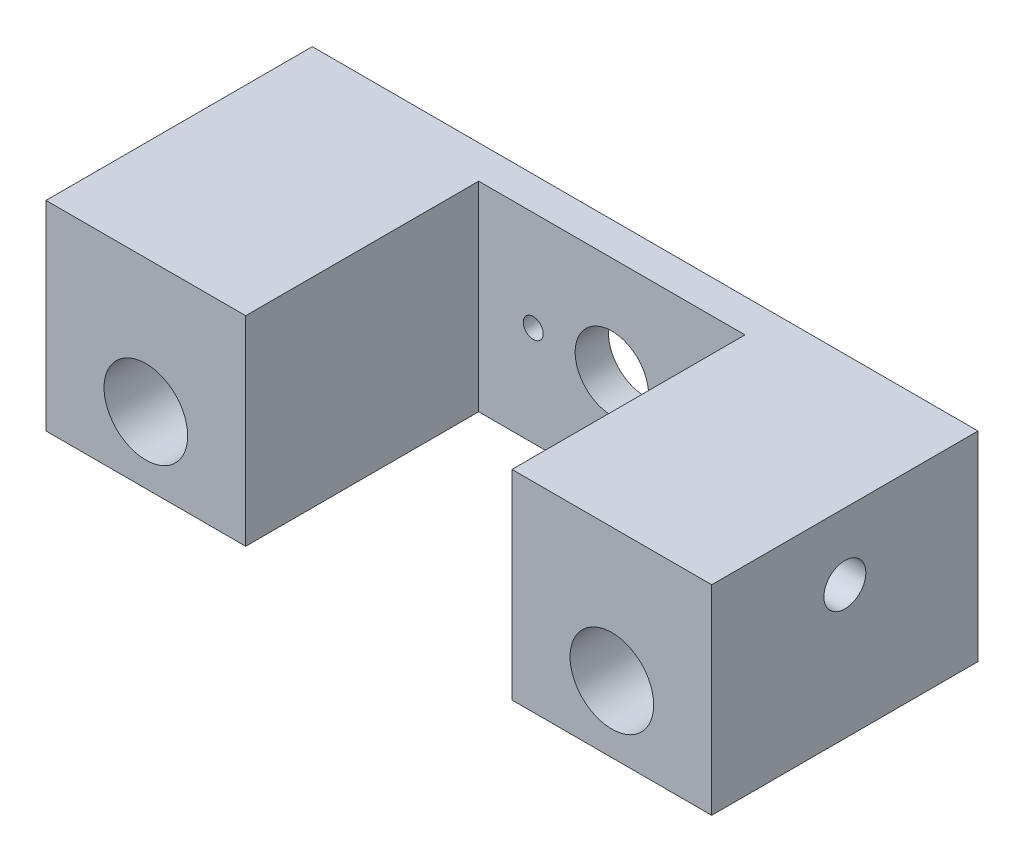
from build123d import *

# Parameters (mm, degrees)
SKETCH1_W           = 63.5
SKETCH1_H           = 19.05
SKETCH1_R           = 3.9878
BOSS_EXTRUDE1_DEPTH = 25.4
SKETCH2_R           = 2
CUT_EXTRUDE1_DEPTH  = 6.35
SKETCH3_W           = 25.4
SKETCH3_H           = 19.05
CUT_EXTRUDE2_DEPTH  = 22.225
SKETCH6_R           = 0.95
SKETCH6_R_2         = 3.5
CUT_EXTRUDE3_DEPTH  = 4.175


with BuildPart() as part:
    # Sketch1 → Boss-Extrude1 (new body)
    with BuildSketch(Plane.XY):
        Rectangle(SKETCH1_W, SKETCH1_H)
        with Locations((-22.225, -3.175)):
            Circle(SKETCH1_R, mode=Mode.SUBTRACT)
        with Locations((22.225, -3.175)):
            Circle(SKETCH1_R, mode=Mode.SUBTRACT)
    extrude(amount=-BOSS_EXTRUDE1_DEPTH)

    # Sketch2 → Cut-Extrude1 (cut)
    with BuildSketch(Plane.ZY.offset(31.75)):
        with Locations((-12.7, 3.175)):
            Circle(SKETCH2_R)
    cut_extrude1 = extrude(amount=-CUT_EXTRUDE1_DEPTH, mode=Mode.SUBTRACT)

    # Mirror1: Cut-Extrude1 across plane
    add(cut_extrude1.mirror(Plane.ZY), mode=Mode.SUBTRACT)

    # Sketch3 → Cut-Extrude2 (cut)
    with BuildSketch(Plane.XY):
        Rectangle(SKETCH3_W, SKETCH3_H)
    extrude(amount=-CUT_EXTRUDE2_DEPTH, mode=Mode.SUBTRACT)

    # Sketch6 → Cut-Extrude3 (cut, through all)
    with BuildSketch(Plane.XY.offset(-22.225)):
        with Locations((-7.5, 0)):
            Circle(SKETCH6_R)
        with Locations((7.5, 0)):
            Circle(SKETCH6_R)
        Circle(SKETCH6_R_2)
    extrude(amount=-CUT_EXTRUDE3_DEPTH, mode=Mode.SUBTRACT)


solid = part.part
